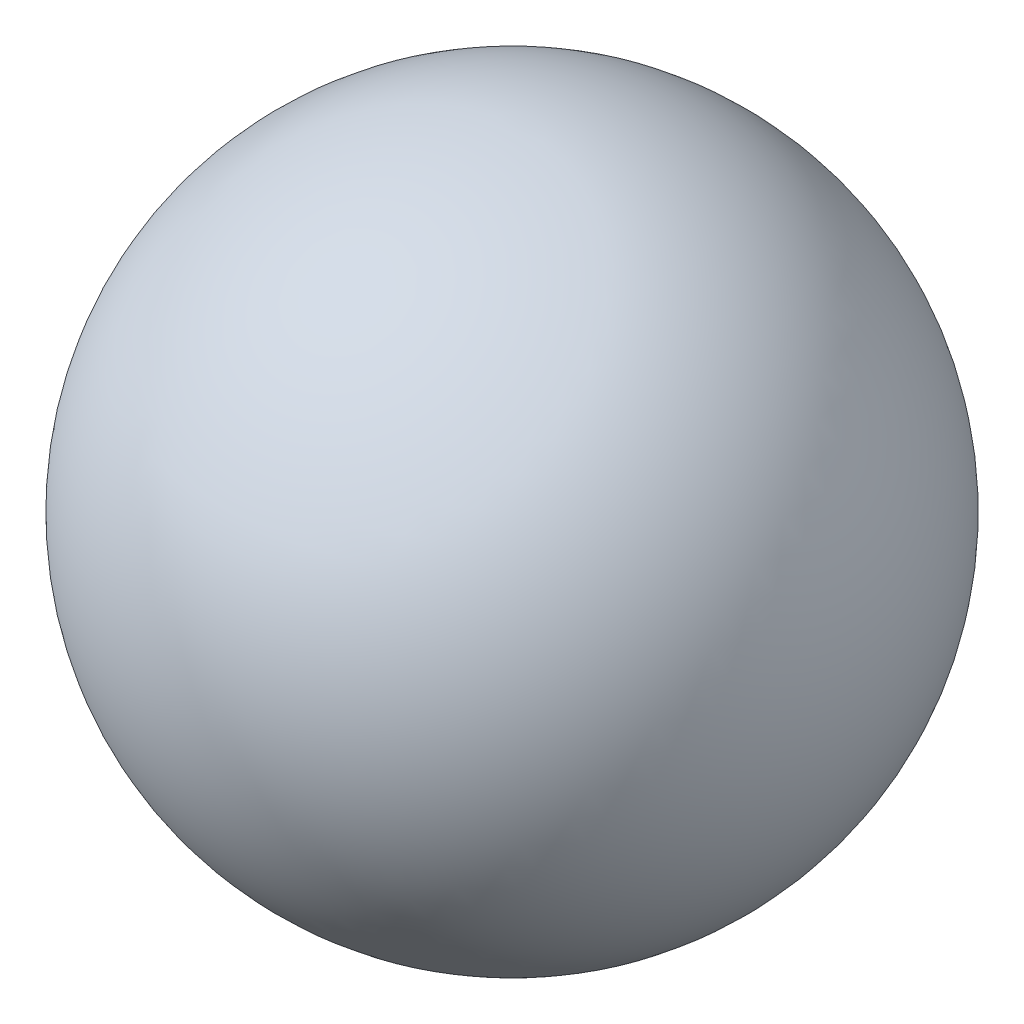
from build123d import *


with BuildPart() as part:
    # Sketch1 → Revolve1 (revolve)
    with BuildSketch(Plane.XY):
        with BuildLine():
            Line((0, 1.995), (0, -1.995))
            ThreePointArc((0, -1.995), (1.995, 0), (0, 1.995))
        make_face()
    revolve(axis=Axis((0, 1.995, 0), (0, -1, 0)))


solid = part.part
